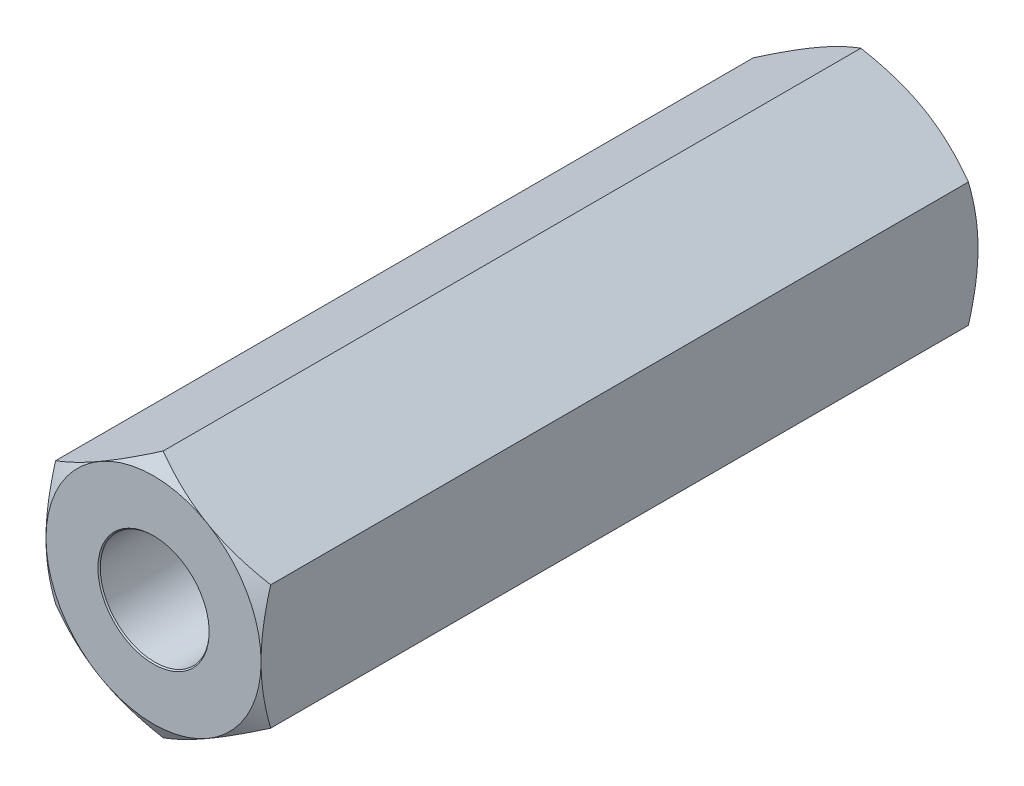
from build123d import *

# Parameters (mm, degrees)
EXTRUDE1_DEPTH          = 15.875
EXTRUDE1_DEPTH_BACK     = 15.875
SKETCH1_R               = 2.413
SKETCH8_OUTSIDE_W       = 134.808
SKETCH8_OUTSIDE_H       = 136.282
SKETCH8_OUTSIDE_R       = 4.7625
EXTRUDE4_DEPTH          = 33.572776689
EXTRUDE4_DRAFT          = -60
MIRROR1_COPY_1_SKETCH_W = 134.808
MIRROR1_COPY_1_SKETCH_H = 136.282
MIRROR1_COPY_1_SKETCH_R = 4.7625
MIRROR1_COPY_1_DEPTH    = 33.572776689
MIRROR1_COPY_1_DRAFT    = -60


with BuildPart() as part:
    # Sketch1 → Extrude1 (new, two sides: drawn at the far end of the back side and taken through both)
    with BuildSketch(Plane.XY.offset(-EXTRUDE1_DEPTH_BACK)):
        Polygon((0, 5.499261314), (-4.7625, 2.749630657), (-4.7625, -2.749630657), (0, -5.499261314), (4.7625, -2.749630657), (4.7625, 2.749630657), align=None)
        Circle(SKETCH1_R, mode=Mode.SUBTRACT)
    extrude(amount=EXTRUDE1_DEPTH + EXTRUDE1_DEPTH_BACK)

    # Extrude3 cone 1 section (through the dimple's axis) → Extrude3 (revolve, cut)
    with BuildSketch(Plane(origin=(0, 0, -15.875), x_dir=(0, 1, 0), z_dir=(1, 0, 0))):
        Polygon((0, 0), (2.4638, 0), (0, 2.642102028), align=None)
    extrude3 = revolve(axis=Axis((0, 0, -15.875), (0, 0, 1)), mode=Mode.SUBTRACT)


with BuildPart() as extrude4_tool:
    # Sketch8 outside → Extrude4 (with draft: the straight prism first)
    with BuildSketch(Plane(origin=(0, 0, -15.875), x_dir=(-1, 0, 0), z_dir=(0, 0, -1))):
        Rectangle(SKETCH8_OUTSIDE_W, SKETCH8_OUTSIDE_H)
        Circle(SKETCH8_OUTSIDE_R, mode=Mode.SUBTRACT)
    extrude(amount=-EXTRUDE4_DEPTH)
    # Extrude4: the draft: its side faces are tilted about the plane it starts from
    extrude4_sides = [extrude4_tool.faces().sort_by_distance(p)[0] for p in [
        (0, -68.141, 0.911388345),
        (-67.404, 0, 0.911388345),
        (0, 68.141, 0.911388345),
        (67.404, 0, 0.911388345),
        (4.7625, 0, 0.911388345),
    ]]
    draft(extrude4_sides, Plane(origin=(0, 0, -15.875), x_dir=(-1, 0, 0), z_dir=(0, 0, -1)), EXTRUDE4_DRAFT)


with BuildPart() as part_1:
    add(part.part)

    # Extrude4: cut by extrude4_tool
    add(extrude4_tool.part, mode=Mode.SUBTRACT)

    # Mirror1: Extrude3 across plane
    add(extrude3.mirror(Plane.XY), mode=Mode.SUBTRACT)


with BuildPart() as mirror1_copy_1_tool:
    # Mirror1 copy 1 sketch → Mirror1 copy 1 (with draft: the straight prism first)
    with BuildSketch(Plane(origin=(0, 0, 15.875), x_dir=(-1, 0, 0), z_dir=(0, 0, 1))):
        Rectangle(MIRROR1_COPY_1_SKETCH_W, MIRROR1_COPY_1_SKETCH_H)
        Circle(MIRROR1_COPY_1_SKETCH_R, mode=Mode.SUBTRACT)
    extrude(amount=-MIRROR1_COPY_1_DEPTH)
    # Mirror1 copy 1: the draft: its side faces are tilted about the plane it starts from
    mirror1_copy_1_sides = [mirror1_copy_1_tool.faces().sort_by_distance(p)[0] for p in [
        (0, -68.141, -0.911388345),
        (-67.404, 0, -0.911388345),
        (0, 68.141, -0.911388345),
        (67.404, 0, -0.911388345),
        (4.7625, 0, -0.911388345),
    ]]
    draft(mirror1_copy_1_sides, Plane(origin=(0, 0, 15.875), x_dir=(-1, 0, 0), z_dir=(0, 0, 1)), MIRROR1_COPY_1_DRAFT)


with BuildPart() as part_2:
    add(part_1.part)

    # Mirror1 copy 1: cut by mirror1_copy_1_tool
    add(mirror1_copy_1_tool.part, mode=Mode.SUBTRACT)


solid = part_2.part
